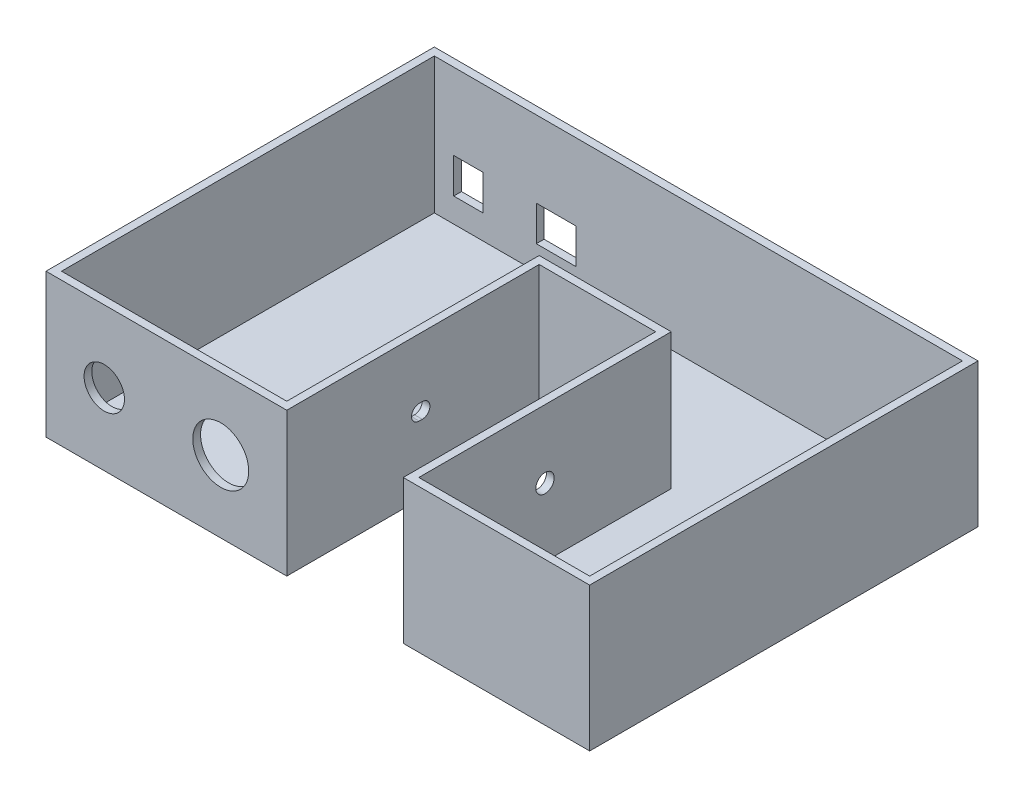
from build123d import *

# Parameters (mm, degrees)
SKETCH1_W           = 78.74
SKETCH1_H           = 127
SKETCH1_W_2         = 38.1
SKETCH1_H_2         = 44.45
BOSS_EXTRUDE1_DEPTH = 2.54
BOSS_EXTRUDE2_DEPTH = 44.45
CUT_EXTRUDE1_REACH  = 129
SKETCH3_W           = 9.5
SKETCH3_H           = 11.5
SKETCH3_W_2         = 13
CUT_EXTRUDE2_REACH  = 103.6
CUT_EXTRUDE3_REACH  = 121.38
SKETCH6_R           = 3
SKETCH29_R          = 9.144
SKETCH29_R_2        = 6.604
CUT_EXTRUDE8_DEPTH  = 2.54


with BuildPart() as part:
    # Sketch1 → Boss-Extrude1 (new body)
    with BuildSketch(Plane(origin=(0, 0, 0), x_dir=(1, 0, 0), z_dir=(0, 1, 0))):
        with Locations((39.37, 63.5)):
            Rectangle(SKETCH1_W, SKETCH1_H)
        with Locations((97.79, 104.775)):
            Rectangle(SKETCH1_W_2, SKETCH1_H_2)
        Polygon((116.84, 127), (116.84, 82.55), (116.84, 0), (177.8, 0), (177.8, 127), align=None)
    extrude(amount=BOSS_EXTRUDE1_DEPTH)

    # Sketch2 → Boss-Extrude2 (add)
    with BuildSketch(Plane(origin=(0, 2.54, 0), x_dir=(1, 0, 0), z_dir=(0, 1, 0))):
        Polygon((0, 127), (0, 0), (78.74, 0), (78.74, 82.55), (116.84, 82.55), (116.84, 0), (177.8, 0), (177.8, 127), align=None)
        Polygon((119.38, 2.54), (175.26, 2.54), (175.26, 124.46), (2.54, 124.46), (2.54, 2.54), (76.2, 2.54), (76.2, 85.09), (119.38, 85.09), align=None, mode=Mode.SUBTRACT)
    extrude(amount=BOSS_EXTRUDE2_DEPTH)

    # Sketch3 → Cut-Extrude1 (cut, up to next)
    with BuildSketch(Plane(origin=(0, 0, -127), x_dir=(-1, 0, 0), z_dir=(0, 0, -1)), mode=Mode.PRIVATE) as cut_extrude1_sk1:
        with Locations((-13.64, 16.24)):
            Rectangle(SKETCH3_W, SKETCH3_H)
    cut_extrude1_tool1 = extrude(cut_extrude1_sk1.sketch, amount=-CUT_EXTRUDE1_REACH, mode=Mode.PRIVATE) & part.part
    add(cut_extrude1_tool1.solids().sort_by_distance((13.64, 16.24, -127))[0], mode=Mode.SUBTRACT)
    # Sketch3 → Cut-Extrude1 (cut, up to next)
    with BuildSketch(Plane(origin=(0, 0, -127), x_dir=(-1, 0, 0), z_dir=(0, 0, -1)), mode=Mode.PRIVATE) as cut_extrude1_sk2:
        with Locations((-42.39, 16.24)):
            Rectangle(SKETCH3_W_2, SKETCH3_H)
    cut_extrude1_tool2 = extrude(cut_extrude1_sk2.sketch, amount=-CUT_EXTRUDE1_REACH, mode=Mode.PRIVATE) & part.part
    add(cut_extrude1_tool2.solids().sort_by_distance((42.39, 16.24, -127))[0], mode=Mode.SUBTRACT)

    # Sketch5 → Cut-Extrude2 (cut, up to next)
    with BuildSketch(Plane.ZY.offset(-76.2), mode=Mode.PRIVATE) as cut_extrude2_sk1:
        with BuildLine():
            Line((-44.315, 27.265), (-43.315, 27.265))
            ThreePointArc((-43.315, 27.265), (-40.815, 24.765), (-43.315, 22.265))
            Line((-43.315, 22.265), (-44.315, 22.265))
            ThreePointArc((-44.315, 22.265), (-46.815, 24.765), (-44.315, 27.265))
        make_face()
    cut_extrude2_tool1 = extrude(cut_extrude2_sk1.sketch, amount=-CUT_EXTRUDE2_REACH, mode=Mode.PRIVATE) & part.part
    add(cut_extrude2_tool1.solids().sort_by_distance((76.2, 24.765, -43.815))[0], mode=Mode.SUBTRACT)

    # Sketch6 → Cut-Extrude3 (cut, up to next)
    with BuildSketch(Plane(origin=(119.38, 0, 0), x_dir=(0, 0, -1), z_dir=(1, 0, 0)), mode=Mode.PRIVATE) as cut_extrude3_sk1:
        with Locations((43.815, 24.765)):
            Circle(SKETCH6_R)
    cut_extrude3_tool1 = extrude(cut_extrude3_sk1.sketch, amount=-CUT_EXTRUDE3_REACH, mode=Mode.PRIVATE) & part.part
    add(cut_extrude3_tool1.solids().sort_by_distance((119.38, 24.765, -43.815))[0], mode=Mode.SUBTRACT)

    # Sketch29 → Cut-Extrude8 (cut)
    with BuildSketch(Plane.XY):
        with Locations((57.15, 23.495)):
            Circle(SKETCH29_R)
        with Locations((19.05, 23.495)):
            Circle(SKETCH29_R_2)
    extrude(amount=-CUT_EXTRUDE8_DEPTH, mode=Mode.SUBTRACT)


solid = part.part
